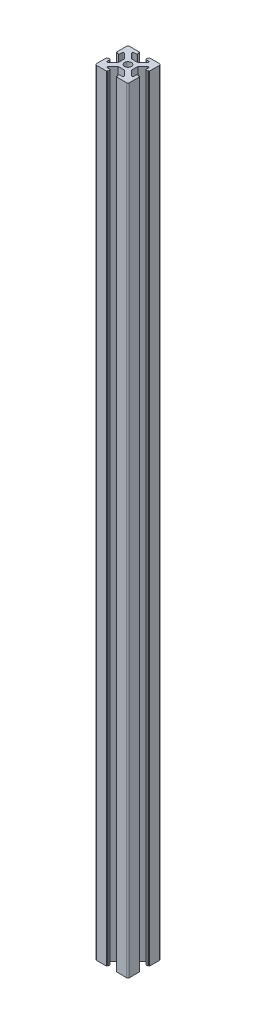
from build123d import *

# Parameters (mm, degrees)
SKETCH_1_R      = 2.1
EXTRUDE_1_DEPTH = 470


with BuildPart() as part:
    # 스케치1 → 보스-돌출1 (new body)
    with BuildSketch(Plane(origin=(0, 0, 0), x_dir=(1, 0, 0), z_dir=(0, 1, 0))):
        with BuildLine():
            Line((2, -4), (-2, -4))
            Line((-2, -4), (-5, -7))
            Line((-5, -7), (-5, -7.5))
            ThreePointArc((-5, -7.5), (-4.853553391, -7.853553391), (-4.5, -8))
            Line((-4.5, -8), (-3.1, -8))
            ThreePointArc((-3.1, -8), (-2.746446609, -8.146446609), (-2.6, -8.5))
            Line((-2.6, -8.5), (-2.6, -9.5))
            Line((-2.6, -9.5), (-3.1, -9.5))
            Line((-3.1, -9.5), (-3.1, -10))
            Line((-3.1, -10), (-9, -10))
            ThreePointArc((-9, -10), (-9.382683432, -9.923879533), (-9.707106781, -9.707106781))
            ThreePointArc((-9.707106781, -9.707106781), (-9.923879533, -9.382683432), (-10, -9))
            Line((-10, -9), (-10, -3.1))
            Line((-10, -3.1), (-9.5, -3.1))
            Line((-9.5, -3.1), (-9.5, -2.6))
            Line((-9.5, -2.6), (-8.5, -2.6))
            ThreePointArc((-8.5, -2.6), (-8.146446609, -2.746446609), (-8, -3.1))
            Line((-8, -3.1), (-8, -4.5))
            ThreePointArc((-8, -4.5), (-7.853553391, -4.853553391), (-7.5, -5))
            Line((-7.5, -5), (-7, -5))
            Line((-7, -5), (-4, -2))
            Line((-4, -2), (-4, 2))
            Line((-4, 2), (-7, 5))
            Line((-7, 5), (-7.5, 5))
            ThreePointArc((-7.5, 5), (-7.853553391, 4.853553391), (-8, 4.5))
            Line((-8, 4.5), (-8, 3.1))
            ThreePointArc((-8, 3.1), (-8.146446609, 2.746446609), (-8.5, 2.6))
            Line((-8.5, 2.6), (-9.5, 2.6))
            Line((-9.5, 2.6), (-9.5, 3.1))
            Line((-9.5, 3.1), (-10, 3.1))
            Line((-10, 3.1), (-10, 9))
            ThreePointArc((-10, 9), (-9.923879533, 9.382683432), (-9.707106781, 9.707106781))
            ThreePointArc((-9.707106781, 9.707106781), (-9.382683432, 9.923879533), (-9, 10))
            Line((-9, 10), (-3.1, 10))
            Line((-3.1, 10), (-3.1, 9.5))
            Line((-3.1, 9.5), (-2.6, 9.5))
            Line((-2.6, 9.5), (-2.6, 8.5))
            ThreePointArc((-2.6, 8.5), (-2.746446609, 8.146446609), (-3.1, 8))
            Line((-3.1, 8), (-4.5, 8))
            ThreePointArc((-4.5, 8), (-4.853553391, 7.853553391), (-5, 7.5))
            Line((-5, 7.5), (-5, 7))
            Line((-5, 7), (-2, 4))
            Line((-2, 4), (2, 4))
            Line((2, 4), (5, 7))
            Line((5, 7), (5, 7.5))
            ThreePointArc((5, 7.5), (4.853553391, 7.853553391), (4.5, 8))
            Line((4.5, 8), (3.1, 8))
            ThreePointArc((3.1, 8), (2.746446609, 8.146446609), (2.6, 8.5))
            Line((2.6, 8.5), (2.6, 9.5))
            Line((2.6, 9.5), (3.1, 9.5))
            Line((3.1, 9.5), (3.1, 10))
            Line((3.1, 10), (9, 10))
            ThreePointArc((9, 10), (9.382683432, 9.923879533), (9.707106781, 9.707106781))
            ThreePointArc((9.707106781, 9.707106781), (9.923879533, 9.382683432), (10, 9))
            Line((10, 9), (10, 3.1))
            Line((10, 3.1), (9.5, 3.1))
            Line((9.5, 3.1), (9.5, 2.6))
            Line((9.5, 2.6), (8.5, 2.6))
            ThreePointArc((8.5, 2.6), (8.146446609, 2.746446609), (8, 3.1))
            Line((8, 3.1), (8, 4.5))
            ThreePointArc((8, 4.5), (7.853553391, 4.853553391), (7.5, 5))
            Line((7.5, 5), (7, 5))
            Line((7, 5), (4, 2))
            Line((4, 2), (4, -2))
            Line((4, -2), (7, -5))
            Line((7, -5), (7.5, -5))
            ThreePointArc((7.5, -5), (7.853553391, -4.853553391), (8, -4.5))
            Line((8, -4.5), (8, -3.1))
            ThreePointArc((8, -3.1), (8.146446609, -2.746446609), (8.5, -2.6))
            Line((8.5, -2.6), (9.5, -2.6))
            Line((9.5, -2.6), (9.5, -3.1))
            Line((9.5, -3.1), (10, -3.1))
            Line((10, -3.1), (10, -9))
            ThreePointArc((10, -9), (9.923879533, -9.382683432), (9.707106781, -9.707106781))
            ThreePointArc((9.707106781, -9.707106781), (9.382683432, -9.923879533), (9, -10))
            Line((9, -10), (3.1, -10))
            Line((3.1, -10), (3.1, -9.5))
            Line((3.1, -9.5), (2.6, -9.5))
            Line((2.6, -9.5), (2.6, -8.5))
            ThreePointArc((2.6, -8.5), (2.746446609, -8.146446609), (3.1, -8))
            Line((3.1, -8), (4.5, -8))
            ThreePointArc((4.5, -8), (4.853553391, -7.853553391), (5, -7.5))
            Line((5, -7.5), (5, -7))
            Line((5, -7), (2, -4))
        make_face()
        Circle(SKETCH_1_R, mode=Mode.SUBTRACT)
    extrude(amount=EXTRUDE_1_DEPTH)


solid = part.part
